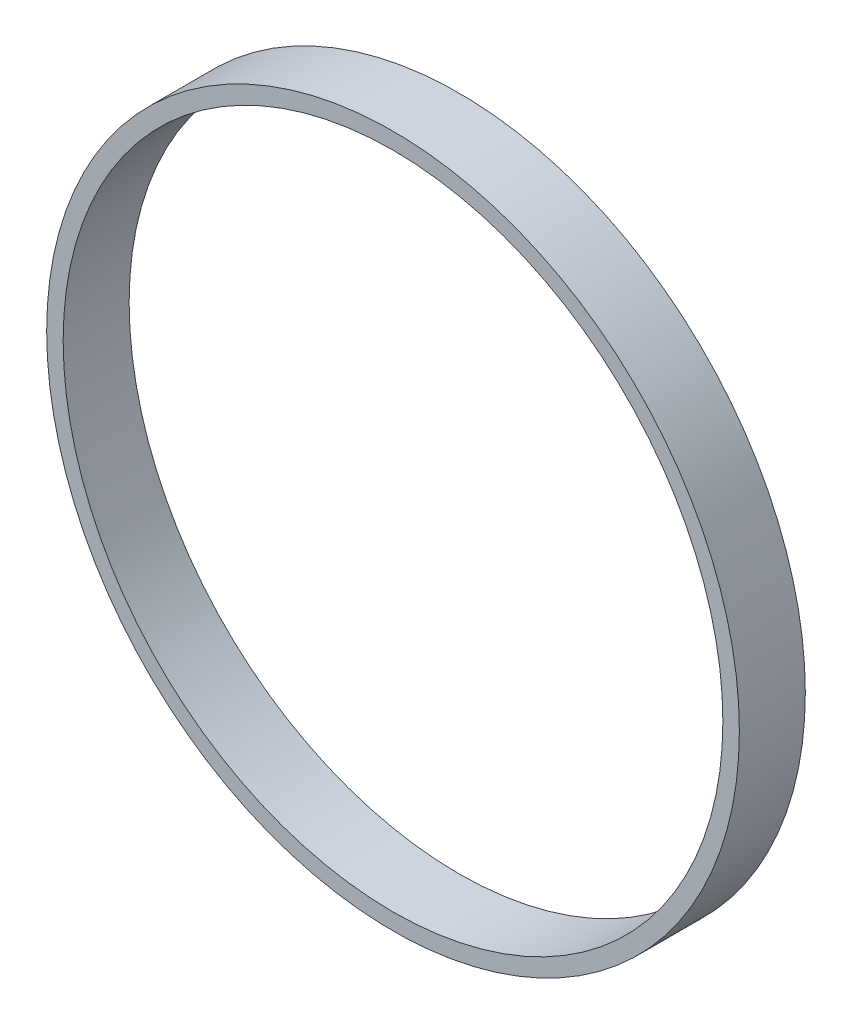
from build123d import *

# Parameters (mm, degrees)
SKETCH1_R           = 105
SKETCH1_R_2         = 100
BOSS_EXTRUDE1_DEPTH = 20


with BuildPart() as part:
    # Sketch1 → Boss-Extrude1 (new body)
    with BuildSketch(Plane.XY):
        Circle(SKETCH1_R)
        Circle(SKETCH1_R_2, mode=Mode.SUBTRACT)
    extrude(amount=BOSS_EXTRUDE1_DEPTH)


solid = part.part
